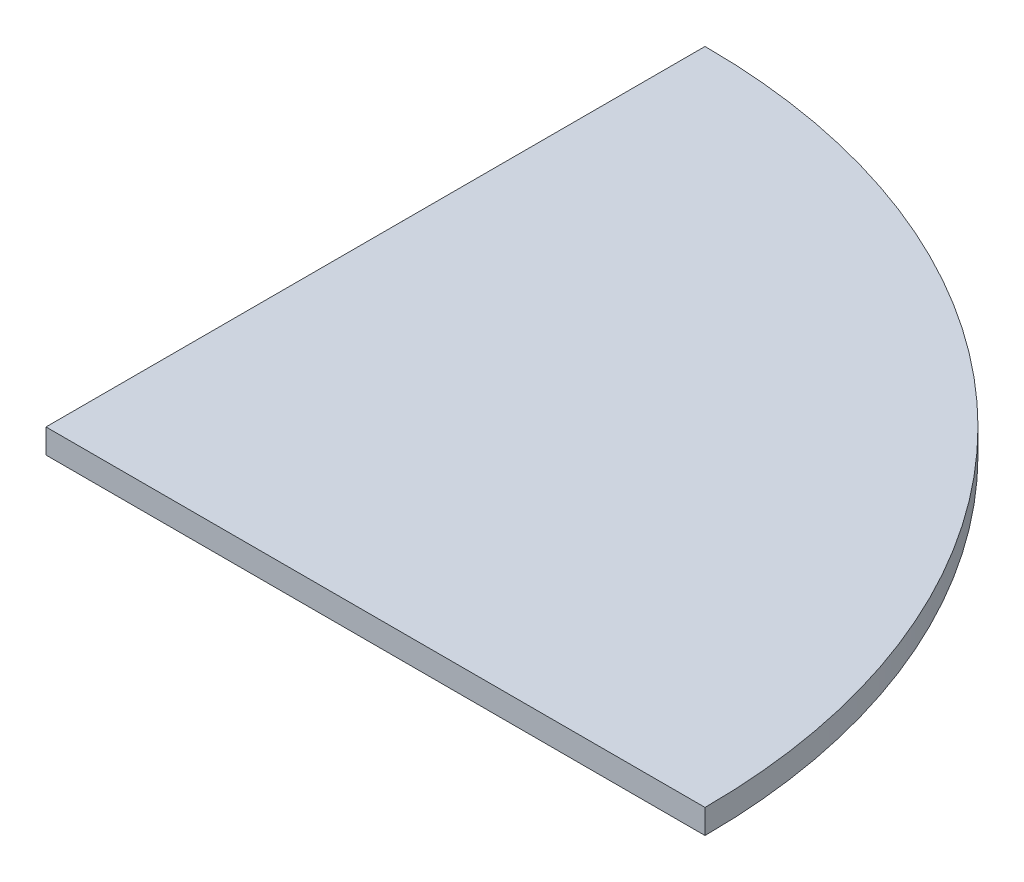
from build123d import *

# Parameters (mm, degrees)
BOSS_EXTRUDE1_DEPTH = 11.43


with BuildPart() as part:
    # Sketch1 → Boss-Extrude1 (new body, symmetric)
    with BuildSketch(Plane(origin=(0, 0, 0), x_dir=(1, 0, 0), z_dir=(0, 1, 0))):
        with BuildLine():
            Line((0, 618.236), (0, 0))
            Line((0, 0), (618.236, 0))
            ThreePointArc((618.236, 0), (437.158867974, 437.158867974), (0, 618.236))
        make_face()
    extrude(amount=BOSS_EXTRUDE1_DEPTH, both=True)


solid = part.part
